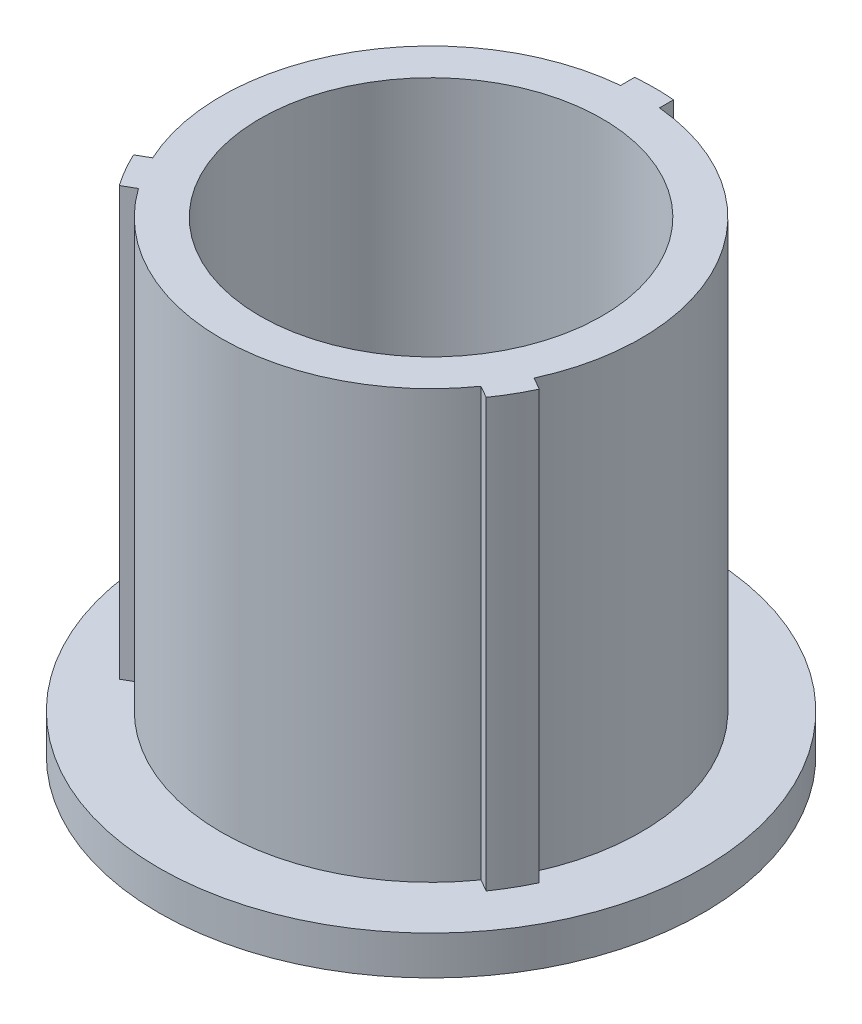
from build123d import *

# Parameters (mm, degrees)
BOSS_EXTRUDE1_DEPTH = 19.05
SKETCH6_W           = 0.608326788
SKETCH6_H           = 1.5875
SKETCH8_W           = 2.576826788
SKETCH8_H           = 1.5875
SKETCH12_R          = 6.985
CUT_EXTRUDE7_DEPTH  = 17.018
SKETCH13_R          = 4.826
CUT_EXTRUDE8_DEPTH  = 20.05


with BuildPart() as part:
    # Sketch1 → Boss-Extrude1 (new body)
    with BuildSketch(Plane(origin=(0, 0, 0), x_dir=(1, 0, 0), z_dir=(0, 1, 0))):
        with BuildLine():
            Line((-0.79375, 9.109483901), (-0.79375, 8.535673212))
            ThreePointArc((-0.79375, 8.535673212), (-7.424002774, 4.28625), (-7.78898484, -3.580428942))
            Line((-7.78898484, -3.580428942), (-8.285919473, -3.867334286))
            ThreePointArc((-8.285919473, -3.867334286), (-7.918936292, -4.572), (-7.492169473, -5.242149615))
            Line((-7.492169473, -5.242149615), (-6.99523484, -4.95524427))
            ThreePointArc((-6.99523484, -4.95524427), (0, -8.5725), (6.99523484, -4.95524427))
            Line((6.99523484, -4.95524427), (7.492169473, -5.242149615))
            ThreePointArc((7.492169473, -5.242149615), (7.918936292, -4.572), (8.285919473, -3.867334286))
            Line((8.285919473, -3.867334286), (7.78898484, -3.580428942))
            ThreePointArc((7.78898484, -3.580428942), (7.424002774, 4.28625), (0.79375, 8.535673212))
            Line((0.79375, 8.535673212), (0.79375, 9.109483901))
            ThreePointArc((0.79375, 9.109483901), (0, 9.144), (-0.79375, 9.109483901))
        make_face()
    extrude(amount=BOSS_EXTRUDE1_DEPTH)

    # Sketch6 → Cut-Revolve2 (revolve, cut)
    with BuildSketch(Plane(origin=(0, 0, 0), x_dir=(0, 0, -1), z_dir=(1, 0, 0))):
        with Locations((8.839836606, 0.79375)):
            Rectangle(SKETCH6_W, SKETCH6_H)
    revolve(axis=Axis((0, 19.730213777, 0), (0, -1, 0)), mode=Mode.SUBTRACT)

    # Sketch8 → Revolve2 (revolve)
    with BuildSketch(Plane(origin=(0, 0, 0), x_dir=(0, 0, -1), z_dir=(1, 0, 0))):
        with Locations((9.824086606, 0.79375)):
            Rectangle(SKETCH8_W, SKETCH8_H)
    revolve(axis=Axis((0, 4.48386458, 0), (0, -1, 0)))

    # Sketch12 → Cut-Extrude7 (cut)
    with BuildSketch(Plane(origin=(0, 19.05, 0), x_dir=(1, 0, 0), z_dir=(0, 1, 0))):
        Circle(SKETCH12_R)
    extrude(amount=-CUT_EXTRUDE7_DEPTH, mode=Mode.SUBTRACT)

    # Sketch13 → Cut-Extrude8 (cut, through all)
    with BuildSketch(Plane.XZ):
        Circle(SKETCH13_R)
    extrude(amount=-CUT_EXTRUDE8_DEPTH, mode=Mode.SUBTRACT)


solid = part.part
